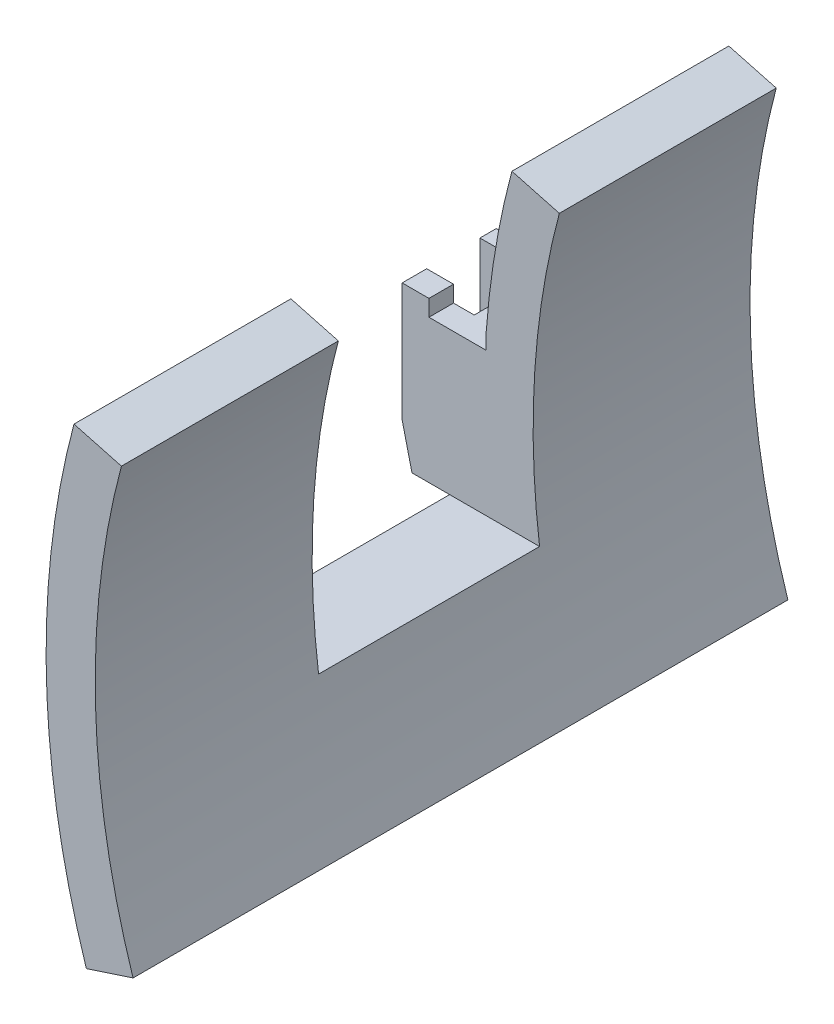
from build123d import *

# Parameters (mm, degrees)
BOSS_EXTRUDE2_DEPTH      = 40
BOSS_EXTRUDE2_DEPTH_BACK = 40
SKETCH5_W                = 50
SKETCH5_H                = 30
BOSS_EXTRUDE1_DEPTH      = 10
BOSS_EXTRUDE1_DEPTH_BACK = 4
SKETCH6_W                = 33
SKETCH6_H                = 6.7
SKETCH6_W_2              = 6.5
SKETCH6_H_2              = 26.2
CUT_EXTRUDE1_DEPTH       = 5.8
CUT_EXTRUDE2_DEPTH       = 50
SKETCH8_W                = 7
SKETCH8_H                = 2
CUT_EXTRUDE3_DEPTH       = 50
SKETCH9_W                = 27
SKETCH9_H                = 14.5
SKETCH9_H_2              = 5
SKETCH9_H_3              = 24.261575761
CUT_EXTRUDE4_DEPTH       = 21.623624402


with BuildPart() as part:
    # Sketch3 → Boss-Extrude2 (new body, two sides)
    with BuildSketch(Plane.XY) as boss_extrude2_sk:
        with BuildLine():
            ThreePointArc((-90.797027671, 24.32899024), (-93.966810921, -2.497688001), (-89.376375598, -29.11809549))
            Line((-89.376375598, -29.11809549), (-95.081250636, -30.97669733))
            ThreePointArc((-95.081250636, -30.97669733), (-99.964692469, -2.657114895), (-96.592582629, 25.88190451))
            Line((-96.592582629, 25.88190451), (-90.797027671, 24.32899024))
        make_face()
    extrude(amount=BOSS_EXTRUDE2_DEPTH)
    extrude(boss_extrude2_sk.sketch, amount=-BOSS_EXTRUDE2_DEPTH_BACK)

    # Sketch5 → Boss-Extrude1 (add, two sides)
    with BuildSketch(Plane.ZY.offset(100)) as boss_extrude1_sk:
        with Locations((0, -7.635182233)):
            Rectangle(SKETCH5_W, SKETCH5_H)
    extrude(amount=BOSS_EXTRUDE1_DEPTH)
    extrude(boss_extrude1_sk.sketch, amount=-BOSS_EXTRUDE1_DEPTH_BACK)

    # Sketch6 → Cut-Extrude1 (cut)
    with BuildSketch(Plane.ZY.offset(110)):
        with Locations((0, -15.485182233)):
            Rectangle(SKETCH6_W, SKETCH6_H)
        with Locations((-19.75, -5.735182233)):
            Rectangle(SKETCH6_W_2, SKETCH6_H_2)
        with Locations((19.75, -5.735182233)):
            Rectangle(SKETCH6_W_2, SKETCH6_H_2)
    extrude(amount=-CUT_EXTRUDE1_DEPTH, mode=Mode.SUBTRACT)

    # Sketch7 → Cut-Extrude2 (cut)
    with BuildSketch(Plane(origin=(0, 0, -25), x_dir=(-1, 0, 0), z_dir=(0, 0, -1))):
        Polygon((108.2, -22.635182233), (108.2, -14.635182233), (110, -7.135182233), (110, -22.635182233), align=None)
    extrude(amount=-CUT_EXTRUDE2_DEPTH, mode=Mode.SUBTRACT)

    # Sketch8 → Cut-Extrude3 (cut)
    with BuildSketch(Plane(origin=(0, 0, -25), x_dir=(-1, 0, 0), z_dir=(0, 0, -1))):
        with Locations((103.228428541, 6.364817767)):
            Rectangle(SKETCH8_W, SKETCH8_H)
    extrude(amount=-CUT_EXTRUDE3_DEPTH, mode=Mode.SUBTRACT)

    # Sketch9 → Cut-Extrude4 (cut, through all)
    with BuildSketch(Plane.ZY.offset(110)):
        with Locations((0, 0.114817767)):
            Rectangle(SKETCH9_W, SKETCH9_H)
        with Locations((0, -9.635182233)):
            Rectangle(SKETCH9_W, SKETCH9_H_2)
        with Locations((0, 19.495605647)):
            Rectangle(SKETCH9_W, SKETCH9_H_3)
    extrude(amount=-CUT_EXTRUDE4_DEPTH, mode=Mode.SUBTRACT)


solid = part.part
